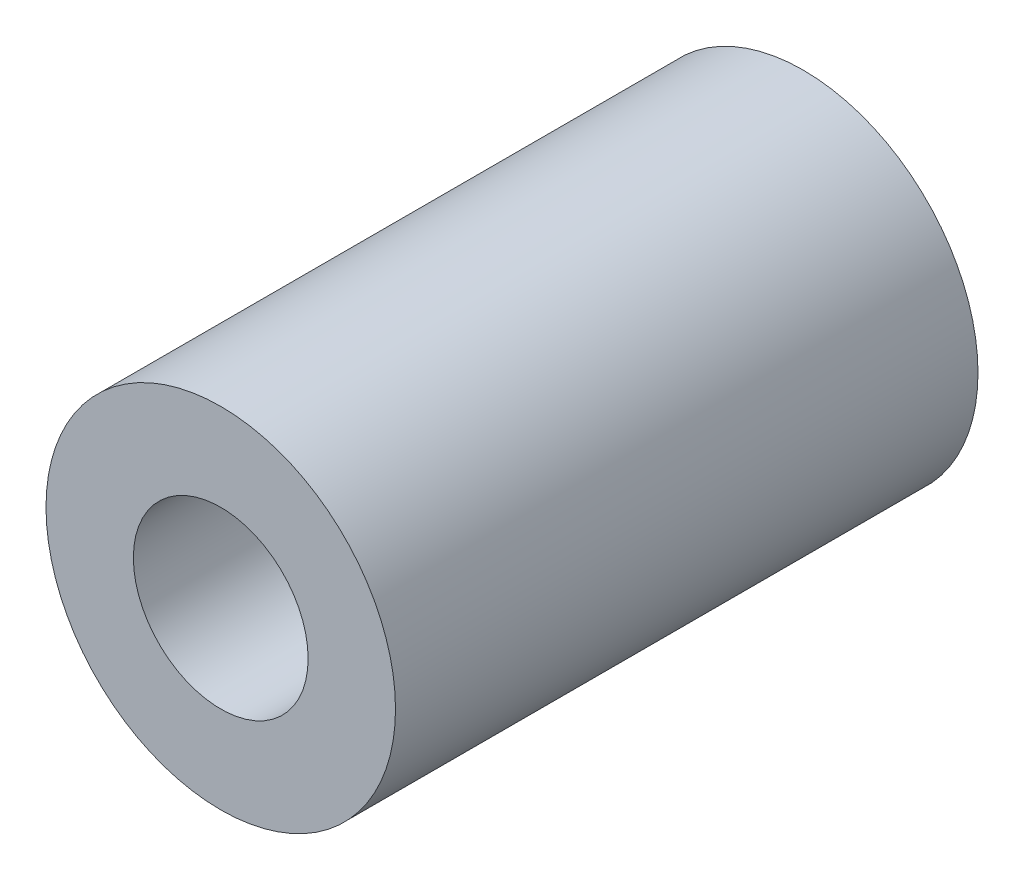
from build123d import *

# Parameters (mm, degrees)
SZKIC1_R                    = 3
SZKIC1_R_2                  = 1.5
DODANIE_WYCI_GNI_CIE1_DEPTH = 10


with BuildPart() as part:
    # Szkic1 → Dodanie-wyciągnięcie1 (new body)
    with BuildSketch(Plane.XY):
        Circle(SZKIC1_R)
        Circle(SZKIC1_R_2, mode=Mode.SUBTRACT)
    extrude(amount=DODANIE_WYCI_GNI_CIE1_DEPTH)


solid = part.part
